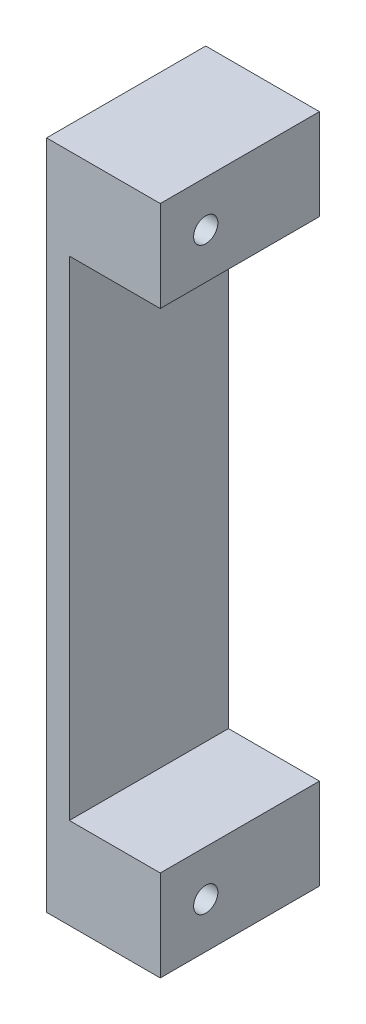
from build123d import *

# Parameters (mm, degrees)
SKETCH1_W                 = 17.78
SKETCH1_H                 = 74.93
BOSS_EXTRUDE1_DEPTH       = 12.7
CUT_EXTRUDE1_DEPTH        = 10.16
TAP_DRILL_FOR_6_32_TAP1_D = 2.7051
SKETCH5_R                 = 2.36855
CUT_EXTRUDE2_DEPTH        = 11.1125


with BuildPart() as part:
    # Sketch1 → Boss-Extrude1 (new body)
    with BuildSketch(Plane(origin=(0, 0, 0), x_dir=(0, 0, -1), z_dir=(1, 0, 0))):
        with Locations((8.89, 37.465)):
            Rectangle(SKETCH1_W, SKETCH1_H)
    extrude(amount=BOSS_EXTRUDE1_DEPTH)

    # Sketch2 → Cut-Extrude1 (cut)
    with BuildSketch(Plane(origin=(12.7, 0, 0), x_dir=(0, 0, -1), z_dir=(1, 0, 0))):
        Polygon((0, 64.77), (10.16, 64.77), (13.97, 64.77), (24.13, 64.77), (24.13, 10.16), (13.97, 10.16), (10.16, 10.16), (0, 10.16), align=None)
    extrude(amount=-CUT_EXTRUDE1_DEPTH, mode=Mode.SUBTRACT)

    # Tap Drill for #6-32 Tap1 (through all)
    with Locations(Plane(origin=(12.7, 0, 0), x_dir=(0, 0, -1), z_dir=(1, 0, 0))):
        with Locations((5.08, 69.85), (5.08, 5.08)):
            Hole(TAP_DRILL_FOR_6_32_TAP1_D / 2)

    # Sketch5 → Cut-Extrude2 (cut)
    with BuildSketch(Plane(origin=(0, 0, -17.78), x_dir=(-1, 0, 0), z_dir=(0, 0, -1))):
        with Locations((-6.35, 69.85)):
            Circle(SKETCH5_R)
        with Locations((-6.35, 5.08)):
            Circle(SKETCH5_R)
    extrude(amount=-CUT_EXTRUDE2_DEPTH, mode=Mode.SUBTRACT)


solid = part.part
